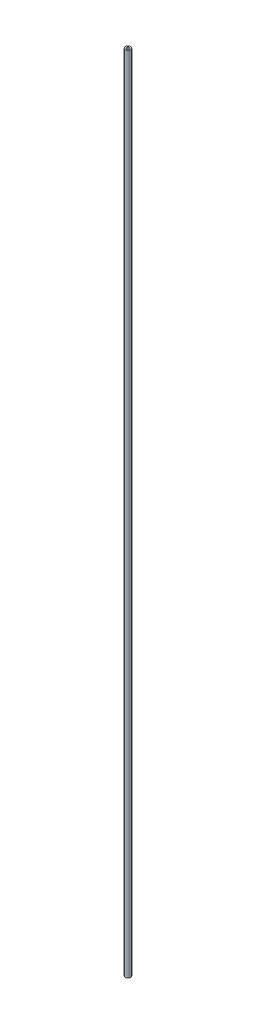
from build123d import *

# Parameters (mm, degrees)
BOSS_EXTRUDE1_DEPTH      = 150
BOSS_EXTRUDE1_DEPTH_BACK = 150
SKETCH1_R                = 1
SKETCH1_R_2              = 0.5


with BuildPart() as part:
    # Sketch1 → Boss-Extrude1 (new, two sides: drawn at the far end of the back side and taken through both)
    with BuildSketch(Plane(origin=(0, 0, 0), x_dir=(1, 0, 0), z_dir=(0, 1, 0)).offset(-BOSS_EXTRUDE1_DEPTH_BACK)):
        Circle(SKETCH1_R)
        Circle(SKETCH1_R_2, mode=Mode.SUBTRACT)
    extrude(amount=BOSS_EXTRUDE1_DEPTH + BOSS_EXTRUDE1_DEPTH_BACK)


solid = part.part
